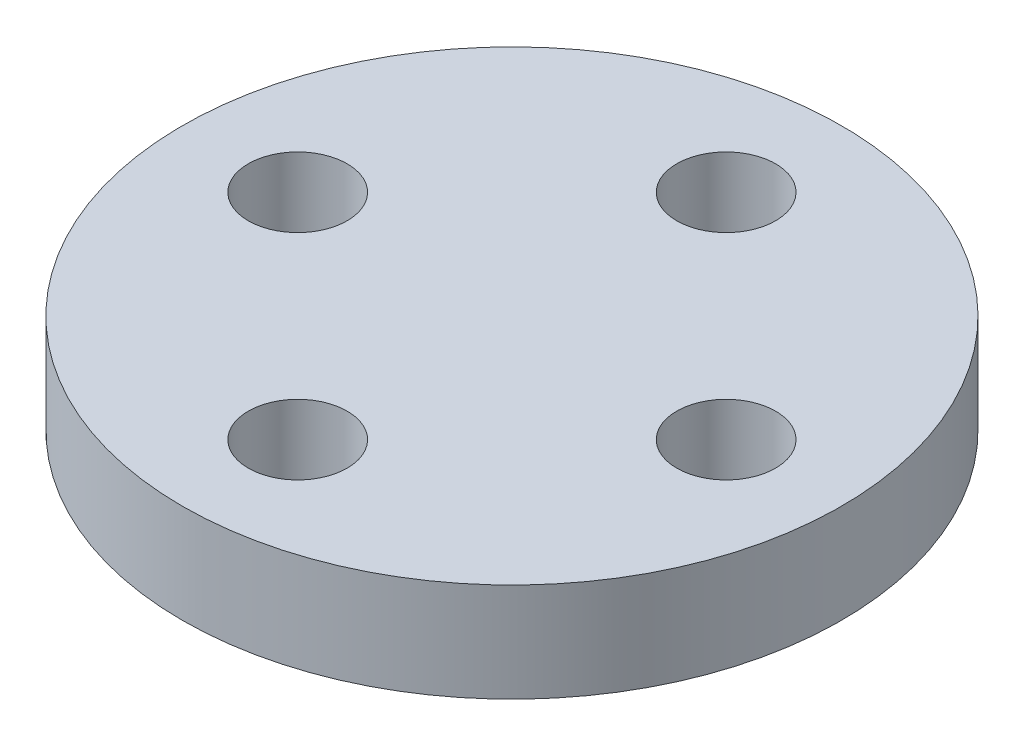
from build123d import *

# Parameters (mm, degrees)
SKETCH2_R           = 10
SKETCH2_R_2         = 1.5
BOSS_EXTRUDE1_DEPTH = 3
SKETCH3_R           = 4
BOSS_EXTRUDE2_DEPTH = 3
SKETCH4_R           = 1.5
CUT_EXTRUDE1_DEPTH  = 3


with BuildPart() as part:
    # Sketch2 → Boss-Extrude1 (new body)
    with BuildSketch(Plane(origin=(0, 0, 0), x_dir=(1, 0, 0), z_dir=(0, 1, 0))):
        Circle(SKETCH2_R)
        with Locations((0, -6.5)):
            Circle(SKETCH2_R_2, mode=Mode.SUBTRACT)
        with Locations((-6.5, 0)):
            Circle(SKETCH2_R_2, mode=Mode.SUBTRACT)
        with Locations((0, 6.5)):
            Circle(SKETCH2_R_2, mode=Mode.SUBTRACT)
        with Locations((6.5, 0)):
            Circle(SKETCH2_R_2, mode=Mode.SUBTRACT)
    extrude(amount=BOSS_EXTRUDE1_DEPTH)

    # Sketch3 → Boss-Extrude2 (add)
    with BuildSketch(Plane(origin=(0, 0, 0), x_dir=(-1, 0, 0), z_dir=(0, -1, 0))):
        Circle(SKETCH3_R)
    extrude(amount=BOSS_EXTRUDE2_DEPTH)

    # Sketch4 → Cut-Extrude1 (cut)
    with BuildSketch(Plane.XZ.offset(3)):
        Circle(SKETCH4_R)
    extrude(amount=-CUT_EXTRUDE1_DEPTH, mode=Mode.SUBTRACT)


solid = part.part
